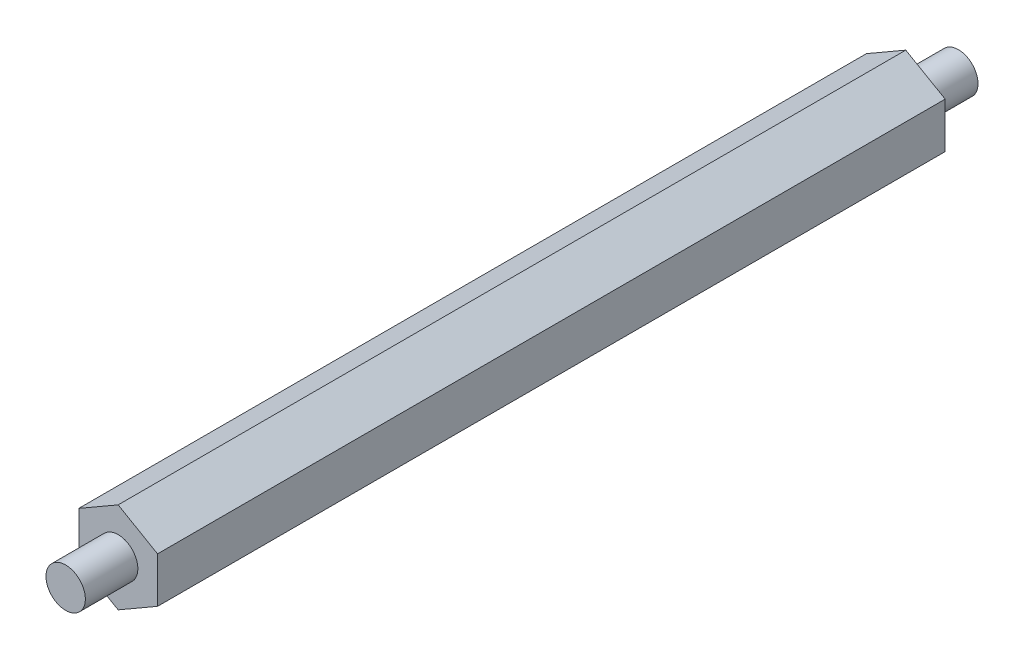
from build123d import *

# Parameters (mm, degrees)
BOSS_EXTRUDE1_DEPTH = 60
SKETCH2_R           = 1.5
BOSS_EXTRUDE2_DEPTH = 4
SKETCH3_R           = 1.5
BOSS_EXTRUDE3_DEPTH = 4


with BuildPart() as part:
    # Sketch1 → Boss-Extrude1 (new body)
    with BuildSketch(Plane.XY):
        Polygon((-0.918598934, -3.331524887), (2.081401066, -1.599474079), (2.081401066, 1.864627536), (-0.918598934, 3.596678344), (-3.918598934, 1.864627536), (-3.918598934, -1.599474079), align=None)
    extrude(amount=BOSS_EXTRUDE1_DEPTH)

    # Sketch2 → Boss-Extrude2 (add)
    with BuildSketch(Plane.XY.offset(60)):
        with Locations((-0.918598934, 0.132576728)):
            Circle(SKETCH2_R)
    extrude(amount=BOSS_EXTRUDE2_DEPTH)

    # Sketch3 → Boss-Extrude3 (add)
    with BuildSketch(Plane(origin=(0, 0, 0), x_dir=(-1, 0, 0), z_dir=(0, 0, -1))):
        with Locations((0.918598934, 0.132576728)):
            Circle(SKETCH3_R)
    extrude(amount=BOSS_EXTRUDE3_DEPTH)


solid = part.part
